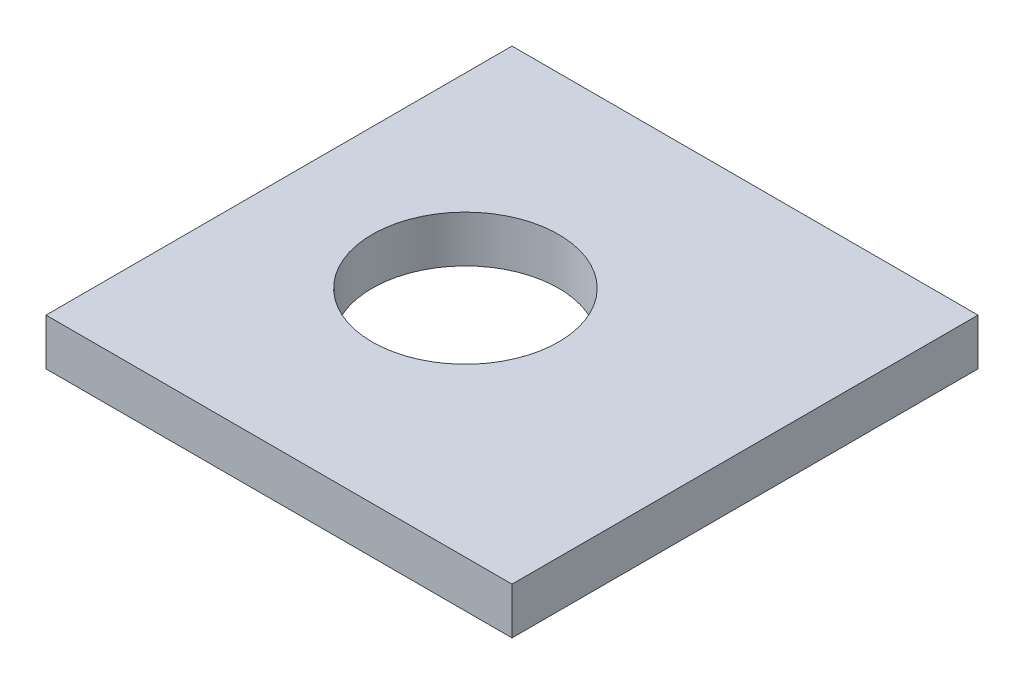
from build123d import *

# Parameters (mm, degrees)
SKETCH_1_W          = 30
SKETCH_1_H          = 3
EXTRUDE_1_DEPTH     = 30
SKETCH_2_R          = 6
CUT_EXTRUDE_1_DEPTH = 30


with BuildPart() as part:
    # Эскиз1 → Бобышка-Вытянуть1 (new body)
    with BuildSketch(Plane(origin=(0, 0, 0), x_dir=(0, 0, -1), z_dir=(1, 0, 0))):
        Rectangle(SKETCH_1_W, SKETCH_1_H)
    extrude(amount=EXTRUDE_1_DEPTH)

    # Эскиз2 → Вырез-Вытянуть1 (cut)
    with BuildSketch(Plane(origin=(0, 1.5, 0), x_dir=(1, 0, 0), z_dir=(0, 1, 0))):
        with Locations((12, 0)):
            Circle(SKETCH_2_R)
    extrude(amount=-CUT_EXTRUDE_1_DEPTH, mode=Mode.SUBTRACT)


solid = part.part
